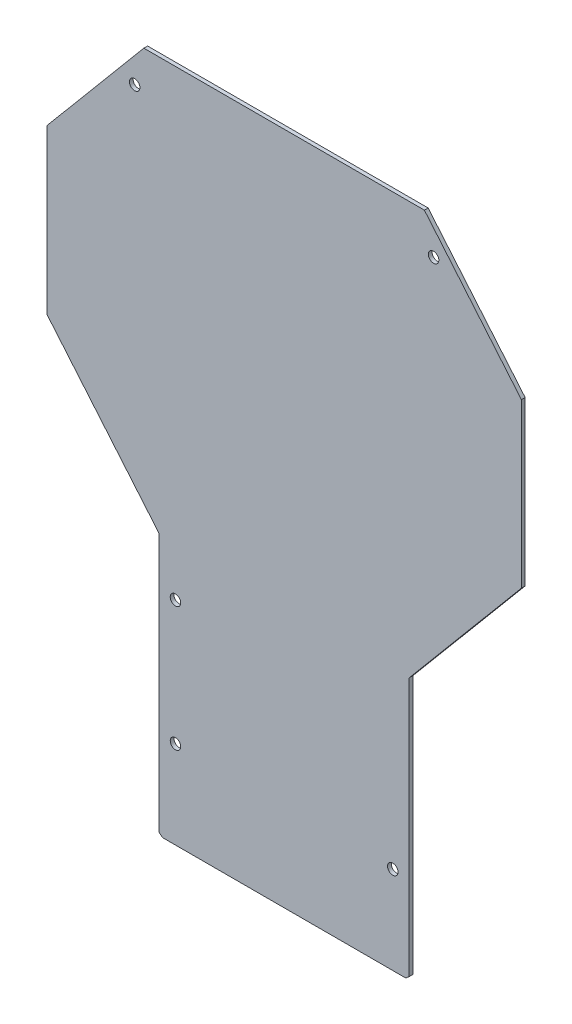
from build123d import *

# Parameters (mm, degrees)
RESSALTO_EXTRUS_O1_DEPTH = 1.5
CORTE_EXTRUS_O1_REACH    = 3.5
ESBO_O2_R                = 2.1


with BuildPart() as part:
    # Esboço1 → Ressalto-extrusão1 (new body)
    with BuildSketch(Plane.XY):
        Polygon((55.321046002, 133.809611411), (-57.006999458, 133.809611411), (-95.842976728, 87.526695978), (-95.842976728, 22.140182404), (-50.842976728, -31.488729263), (-50.842976728, -135.082673958), (-49.522853837, -136.190388589), (47.836900381, -136.190388589), (49.157023272, -135.082673958), (49.157023272, -31.488729263), (94.157023272, 22.140182404), (94.157023272, 87.526695978), align=None)
    extrude(amount=RESSALTO_EXTRUS_O1_DEPTH)

    # Esboço2 → Corte-extrusão1 (cut, up to next)
    with BuildSketch(Plane.XY.offset(1.5), mode=Mode.PRIVATE) as corte_extrus_o1_sk1:
        with Locations((-60.684933322, 119.314215641)):
            Circle(ESBO_O2_R)
    corte_extrus_o1_tool1 = extrude(corte_extrus_o1_sk1.sketch, amount=-CORTE_EXTRUS_O1_REACH, mode=Mode.PRIVATE) & part.part
    add(corte_extrus_o1_tool1.solids().sort_by_distance((-60.684933, 119.314216, 1.5))[0], mode=Mode.SUBTRACT)
    # Esboço2 → Corte-extrusão1 (cut, up to next)
    with BuildSketch(Plane.XY.offset(1.5), mode=Mode.PRIVATE) as corte_extrus_o1_sk2:
        with Locations((-44.342976728, -101.030388589)):
            Circle(ESBO_O2_R)
    corte_extrus_o1_tool2 = extrude(corte_extrus_o1_sk2.sketch, amount=-CORTE_EXTRUS_O1_REACH, mode=Mode.PRIVATE) & part.part
    add(corte_extrus_o1_tool2.solids().sort_by_distance((-44.342977, -101.030389, 1.5))[0], mode=Mode.SUBTRACT)
    # Esboço2 → Corte-extrusão1 (cut, up to next)
    with BuildSketch(Plane.XY.offset(1.5), mode=Mode.PRIVATE) as corte_extrus_o1_sk3:
        with Locations((42.657023272, -101.030388589)):
            Circle(ESBO_O2_R)
    corte_extrus_o1_tool3 = extrude(corte_extrus_o1_sk3.sketch, amount=-CORTE_EXTRUS_O1_REACH, mode=Mode.PRIVATE) & part.part
    add(corte_extrus_o1_tool3.solids().sort_by_distance((42.657023, -101.030389, 1.5))[0], mode=Mode.SUBTRACT)
    # Esboço2 → Corte-extrusão1 (cut, up to next)
    with BuildSketch(Plane.XY.offset(1.5), mode=Mode.PRIVATE) as corte_extrus_o1_sk4:
        with Locations((58.998979866, 119.314215641)):
            Circle(ESBO_O2_R)
    corte_extrus_o1_tool4 = extrude(corte_extrus_o1_sk4.sketch, amount=-CORTE_EXTRUS_O1_REACH, mode=Mode.PRIVATE) & part.part
    add(corte_extrus_o1_tool4.solids().sort_by_distance((58.99898, 119.314216, 1.5))[0], mode=Mode.SUBTRACT)
    # Esboço2 → Corte-extrusão1 (cut, up to next)
    with BuildSketch(Plane.XY.offset(1.5), mode=Mode.PRIVATE) as corte_extrus_o1_sk5:
        with Locations((-44.342976728, -51.190388589)):
            Circle(ESBO_O2_R)
    corte_extrus_o1_tool5 = extrude(corte_extrus_o1_sk5.sketch, amount=-CORTE_EXTRUS_O1_REACH, mode=Mode.PRIVATE) & part.part
    add(corte_extrus_o1_tool5.solids().sort_by_distance((-44.342977, -51.190389, 1.5))[0], mode=Mode.SUBTRACT)


solid = part.part
